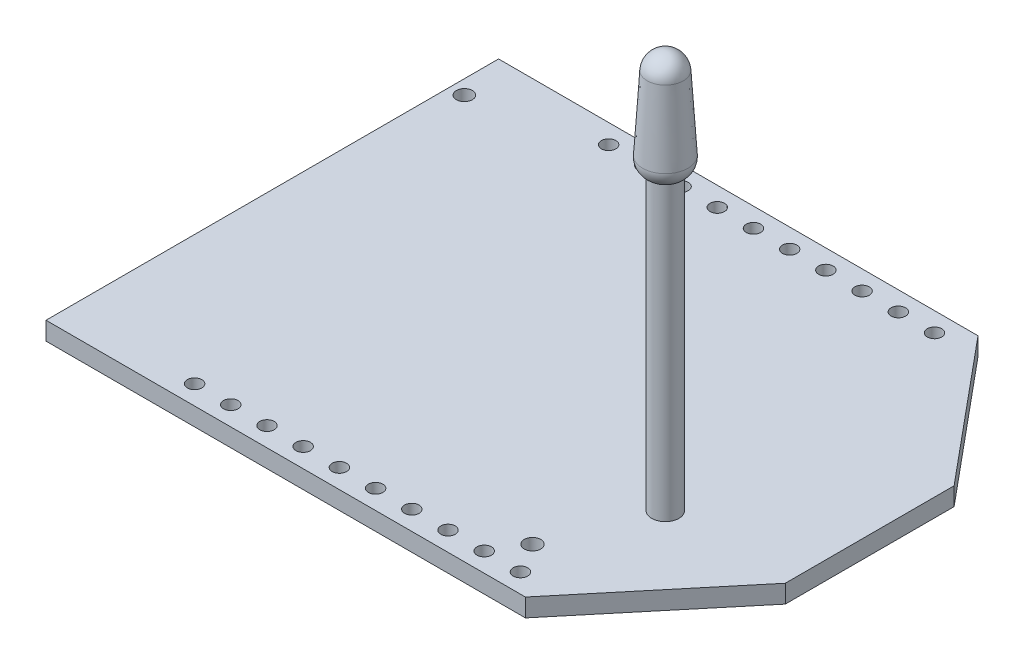
from build123d import *

# Parameters (mm, degrees)
SKETCH1_W           = 33
SKETCH1_H           = 25
BOSS_EXTRUDE1_DEPTH = 1
CUT_EXTRUDE1_DEPTH  = 2
SKETCH3_R           = 0.4
SKETCH3_R_2         = 0.442084783
SKETCH3_R_3         = 0.458227678
CUT_EXTRUDE2_DEPTH  = 2
SKETCH4_R           = 0.75
BOSS_EXTRUDE2_DEPTH = 17
BOSS_EXTRUDE3_DEPTH = 2


with BuildPart() as part:
    # Sketch1 → Boss-Extrude1 (new body)
    with BuildSketch(Plane(origin=(0, 0, 0), x_dir=(1, 0, 0), z_dir=(0, 1, 0))):
        with Locations((16.5, 12.5)):
            Rectangle(SKETCH1_W, SKETCH1_H)
    extrude(amount=BOSS_EXTRUDE1_DEPTH)

    # Sketch2 → Cut-Extrude1 (cut, through all)
    with BuildSketch(Plane.XZ):
        Polygon((33, 0), (26.482981269, 0), (33, -7.837809095), align=None)
        Polygon((33, -17.162190905), (33, -25), (26.482981269, -25), align=None)
    extrude(amount=-CUT_EXTRUDE1_DEPTH, mode=Mode.SUBTRACT)

    # Sketch3 → Cut-Extrude2 (cut, through all)
    with BuildSketch(Plane(origin=(0, 1, 0), x_dir=(1, 0, 0), z_dir=(0, 1, 0))):
        with Locations((7.143852183, 23.936106005)):
            Circle(SKETCH3_R)
        with Locations((9.143852183, 23.936106005)):
            Circle(SKETCH3_R)
        with Locations((11.143852183, 23.936106005)):
            Circle(SKETCH3_R)
        with Locations((13.143852183, 23.936106005)):
            Circle(SKETCH3_R)
        with Locations((15.143852183, 23.936106005)):
            Circle(SKETCH3_R)
        with Locations((17.143852183, 23.936106005)):
            Circle(SKETCH3_R)
        with Locations((19.143852183, 23.936106005)):
            Circle(SKETCH3_R)
        with Locations((21.143852183, 23.936106005)):
            Circle(SKETCH3_R)
        with Locations((23.143852183, 23.936106005)):
            Circle(SKETCH3_R)
        with Locations((25.143852183, 23.936106005)):
            Circle(SKETCH3_R)
        with Locations((25.143852183, 1.063893995)):
            Circle(SKETCH3_R)
        with Locations((23.143852183, 1.063893995)):
            Circle(SKETCH3_R)
        with Locations((21.143852183, 1.063893995)):
            Circle(SKETCH3_R)
        with Locations((19.143852183, 1.063893995)):
            Circle(SKETCH3_R)
        with Locations((17.143852183, 1.063893995)):
            Circle(SKETCH3_R)
        with Locations((15.143852183, 1.063893995)):
            Circle(SKETCH3_R)
        with Locations((13.143852183, 1.063893995)):
            Circle(SKETCH3_R)
        with Locations((11.143852183, 1.063893995)):
            Circle(SKETCH3_R)
        with Locations((9.143852183, 1.063893995)):
            Circle(SKETCH3_R)
        with Locations((7.143852183, 1.063893995)):
            Circle(SKETCH3_R)
        with Locations((0.784299075, 22.325061426)):
            Circle(SKETCH3_R_2)
        with Locations((24.152709784, 2.722277331)):
            Circle(SKETCH3_R_3)
    extrude(amount=-CUT_EXTRUDE2_DEPTH, mode=Mode.SUBTRACT)

    # Sketch4 → Boss-Extrude2 (add)
    with BuildSketch(Plane(origin=(0, 1, 0), x_dir=(1, 0, 0), z_dir=(0, 1, 0))):
        with Locations((26.211922043, 8)):
            Circle(SKETCH4_R)
    extrude(amount=BOSS_EXTRUDE2_DEPTH)

    # Sketch5 → Revolve1 (revolve)
    with BuildSketch(Plane.XY.offset(-8)):
        with BuildLine():
            Line((26.211922043, 18), (26.211922043, 23))
            ThreePointArc((26.211922043, 23), (25.525593233, 22.727999503), (25.211922043, 22.059686783))
            Line((25.211922043, 22.059686783), (24.961922043, 18))
            ThreePointArc((24.961922043, 18), (25.081321038, 17.489279713), (25.461922043, 17.128399944))
            Line((25.461922043, 17.128399944), (25.461922043, 18))
            Line((25.461922043, 18), (26.211922043, 18))
        make_face()
    revolve(axis=Axis((26.211922043, 18, -8), (0, 1, 0)))

    # Sketch6 → Boss-Extrude3 (add)
    with BuildSketch(Plane.XZ):
        with BuildLine():
            Line((24.507853381, -22.428957603), (0.778175079, -22.428957603))
            ThreePointArc((0.778175079, -22.428957603), (0.424621688, -22.282510994), (0.278175079, -21.928957603))
            Line((0.278175079, -21.928957603), (0.278175079, -2.903294195))
            ThreePointArc((0.278175079, -2.903294195), (0.424621688, -2.549740805), (0.778175079, -2.403294195))
            Line((0.778175079, -2.403294195), (24.507853381, -2.403294195))
            ThreePointArc((24.507853381, -2.403294195), (24.861406772, -2.549740805), (25.007853381, -2.903294195))
            Line((25.007853381, -2.903294195), (25.007853381, -21.928957603))
            ThreePointArc((25.007853381, -21.928957603), (24.861406772, -22.282510994), (24.507853381, -22.428957603))
        make_face()
    extrude(amount=BOSS_EXTRUDE3_DEPTH)


solid = part.part
